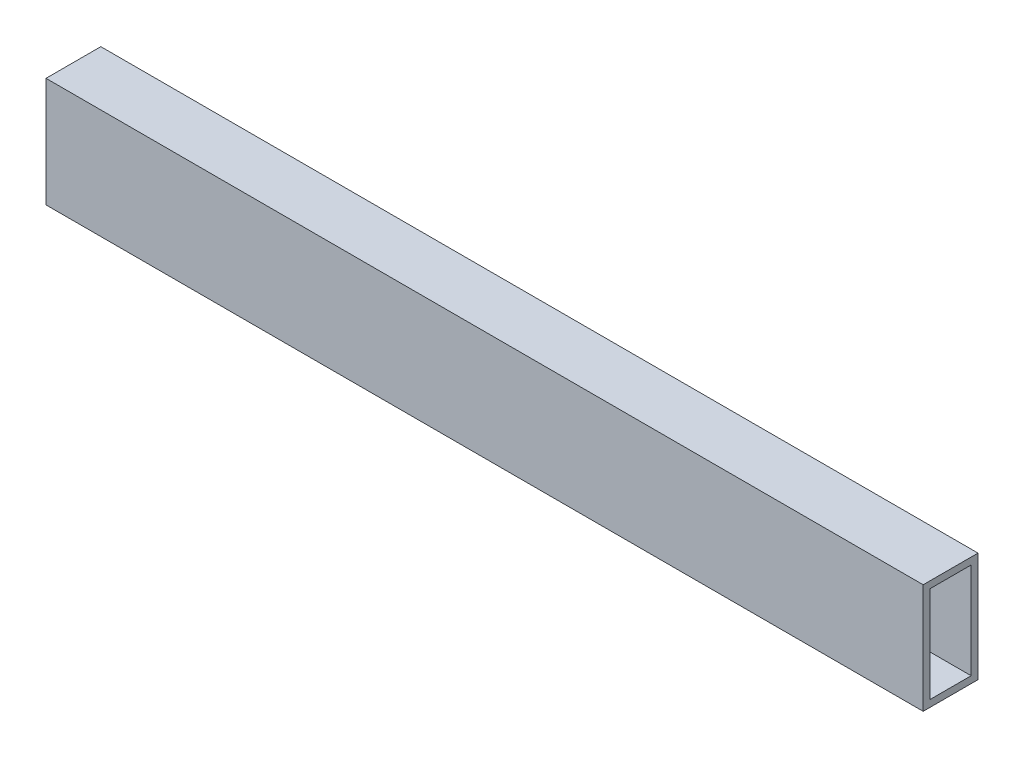
from build123d import *

# Parameters (mm, degrees)
SKETCH1_W           = 406.4
SKETCH1_H           = 25.4
BOSS_EXTRUDE1_DEPTH = 25.4
SHELL1_T            = -3.175


with BuildPart() as part:
    # Sketch1 → Boss-Extrude1 (new body, symmetric)
    with BuildSketch(Plane(origin=(0, 0, 0), x_dir=(1, 0, 0), z_dir=(0, 1, 0))):
        Rectangle(SKETCH1_W, SKETCH1_H)
    extrude(amount=BOSS_EXTRUDE1_DEPTH, both=True)

    # Shell1
    shell1_openings = [part.faces().sort_by_distance(p)[0] for p in [
        (-203.2, 0, 0),
        (203.2, 0, 0),
    ]]
    offset(amount=SHELL1_T, openings=shell1_openings, kind=Kind.INTERSECTION)


solid = part.part
